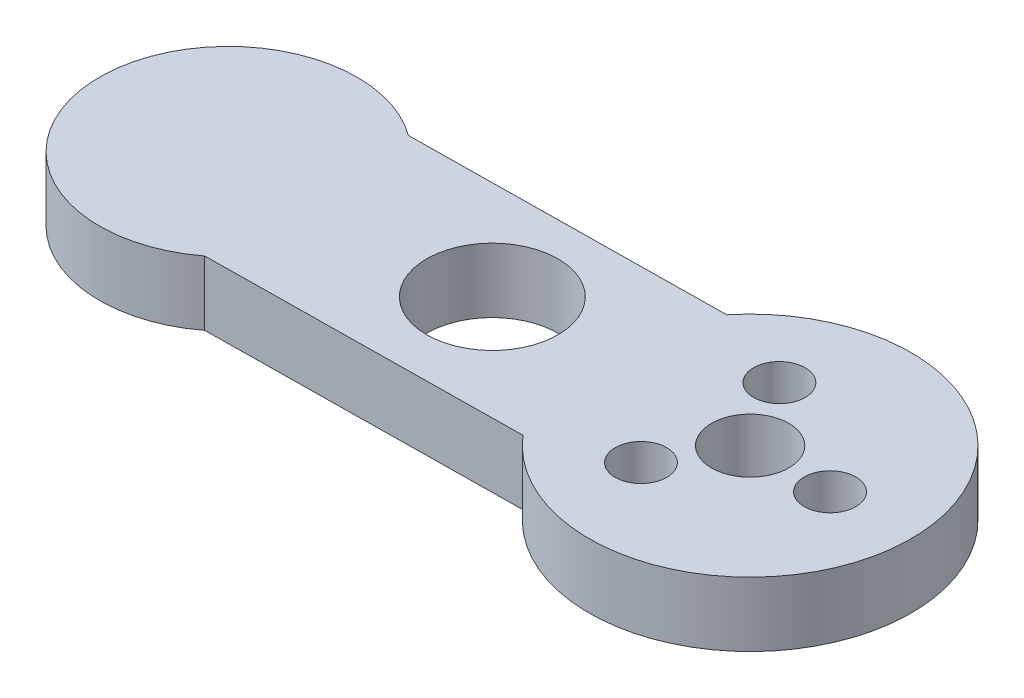
from build123d import *

# Parameters (mm, degrees)
SKETCH1_R           = 5.1
SKETCH1_R_2         = 2
SKETCH1_R_3         = 3
BOSS_EXTRUDE1_DEPTH = 5


with BuildPart() as part:
    # Sketch1 → Boss-Extrude1 (new body)
    with BuildSketch(Plane(origin=(0, 0, 0), x_dir=(1, 0, 0), z_dir=(0, 1, 0))):
        with BuildLine():
            Line((-33.899726562, -8.414780986), (-9.506233548, -8.116743419))
            ThreePointArc((-9.506233548, -8.116743419), (12.499067121, 0.15271251), (-9.701705562, 7.882062496))
            Line((-9.701705562, 7.882062496), (-34.095198575, 7.584024929))
            ThreePointArc((-34.095198575, 7.584024929), (-49.996268483, -0.610850042), (-33.899726562, -8.414780986))
        make_face()
        with Locations((-20, 0)):
            Circle(SKETCH1_R, mode=Mode.SUBTRACT)
        with Locations((-3.1, 5.369357503)):
            Circle(SKETCH1_R_2, mode=Mode.SUBTRACT)
        with Locations((-3.1, -5.369357503)):
            Circle(SKETCH1_R_2, mode=Mode.SUBTRACT)
        Circle(SKETCH1_R_3, mode=Mode.SUBTRACT)
        with Locations((6.2, 0)):
            Circle(SKETCH1_R_2, mode=Mode.SUBTRACT)
    extrude(amount=BOSS_EXTRUDE1_DEPTH)


solid = part.part
